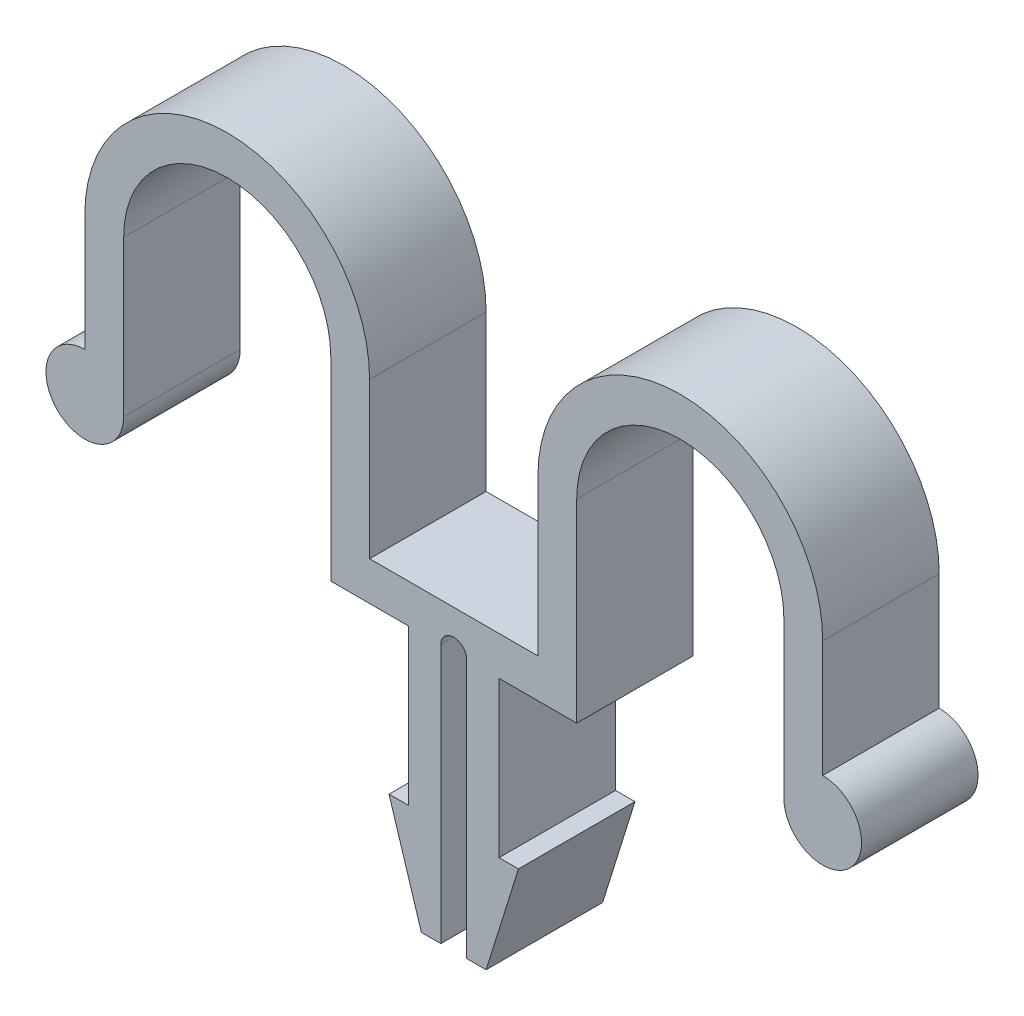
from build123d import *

# Parameters (mm, degrees)
BOSS_EXTRUDE1_DEPTH = 9


with BuildPart() as part:
    # Sketch1 → Boss-Extrude1 (new body)
    with BuildSketch(Plane.XY):
        with BuildLine():
            Line((0, 3), (0, 12))
            ThreePointArc((0, 12), (11, 23), (22, 12))
            Line((22, 12), (22, 0))
            Line((22, 0), (35, 0))
            Line((35, 0), (35, 12))
            ThreePointArc((35, 12), (46, 23), (57, 12))
            Line((57, 12), (57, 3))
            ThreePointArc((57, 3), (59.121320344, -2.121320344), (54, 0))
            Line((54, 0), (54, 12))
            ThreePointArc((54, 12), (46, 20), (38, 12))
            Line((38, 12), (38, -3))
            Line((38, -3), (32, -3))
            Line((32, -3), (32, -15))
            Line((32, -15), (33.5, -15))
            Line((33.5, -15), (31, -23))
            Line((31, -23), (29.5, -23))
            Line((29.5, -23), (29.5, -3))
            ThreePointArc((29.5, -3), (28.5, -2), (27.5, -3))
            Line((27.5, -3), (27.5, -23))
            Line((27.5, -23), (26, -23))
            Line((26, -23), (23.5, -15))
            Line((23.5, -15), (25, -15))
            Line((25, -15), (25, -3))
            Line((25, -3), (19, -3))
            Line((19, -3), (19, 12))
            ThreePointArc((19, 12), (11, 20), (3, 12))
            Line((3, 12), (3, 0))
            ThreePointArc((3, 0), (-2.121320344, -2.121320344), (0, 3))
        make_face()
    extrude(amount=BOSS_EXTRUDE1_DEPTH)


solid = part.part
